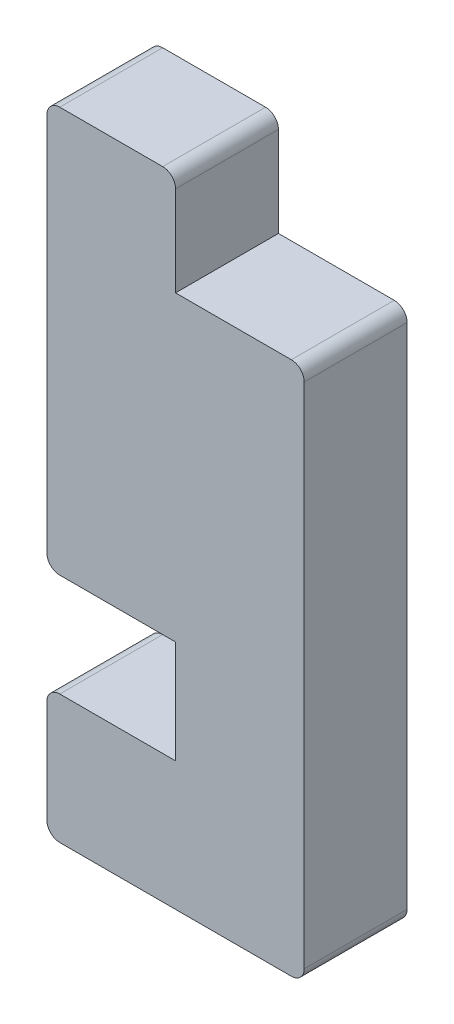
from build123d import *

# Parameters (mm, degrees)
BOSS_EXTRUDE1_DEPTH = 8


with BuildPart() as part:
    # Sketch1 → Boss-Extrude1 (new body)
    with BuildSketch(Plane.XY):
        with BuildLine():
            Line((1, 0), (19, 0))
            ThreePointArc((19, 0), (19.707106781, 0.292893219), (20, 1))
            Line((20, 1), (20, 40.5))
            ThreePointArc((20, 40.5), (19.707106781, 41.207106781), (19, 41.5))
            Line((19, 41.5), (10, 41.5))
            Line((10, 41.5), (10, 48.5))
            ThreePointArc((10, 48.5), (9.707106781, 49.207106781), (9, 49.5))
            Line((9, 49.5), (1, 49.5))
            ThreePointArc((1, 49.5), (0.292893219, 49.207106781), (0, 48.5))
            Line((0, 48.5), (0, 19))
            ThreePointArc((0, 19), (0.292893219, 18.292893219), (1, 18))
            Line((1, 18), (10, 18))
            Line((10, 18), (10, 10))
            Line((10, 10), (1, 10))
            ThreePointArc((1, 10), (0.292893219, 9.707106781), (0, 9))
            Line((0, 9), (0, 1))
            ThreePointArc((0, 1), (0.292893219, 0.292893219), (1, 0))
        make_face()
    extrude(amount=BOSS_EXTRUDE1_DEPTH)


solid = part.part
